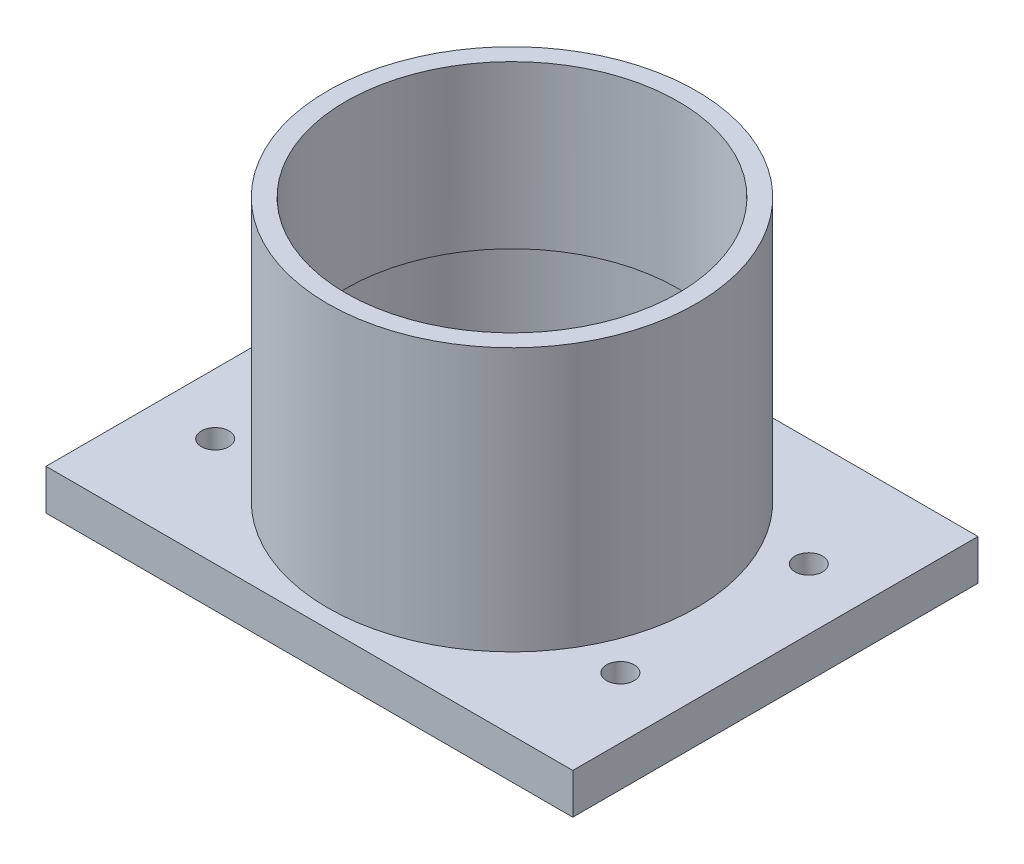
from build123d import *

# Parameters (mm, degrees)
SKETCH1_W             = 130
SKETCH1_H             = 100
BOSS_EXTRUDE1_DEPTH   = 10
SKETCH2_R             = 45.5
BOSS_EXTRUDE2_DEPTH   = 65
SKETCH3_R             = 41
CUT_EXTRUDE1_DEPTH    = 76
SKETCH4_R             = 42.5
CUT_EXTRUDE2_DEPTH    = 35
M8_TAPPED_HOLE1_D     = 6.8
M8_TAPPED_HOLE1_DEPTH = 17.707073895
M8_TAPPED_HOLE1_TIP   = 2.042926105


with BuildPart() as part:
    # Sketch1 → Boss-Extrude1 (new body)
    with BuildSketch(Plane(origin=(0, 0, 0), x_dir=(1, 0, 0), z_dir=(0, 1, 0))):
        Rectangle(SKETCH1_W, SKETCH1_H)
    extrude(amount=BOSS_EXTRUDE1_DEPTH)

    # Sketch2 → Boss-Extrude2 (add)
    with BuildSketch(Plane(origin=(0, 10, 0), x_dir=(1, 0, 0), z_dir=(0, 1, 0))):
        Circle(SKETCH2_R)
    extrude(amount=BOSS_EXTRUDE2_DEPTH)

    # Sketch3 → Cut-Extrude1 (cut, through all)
    with BuildSketch(Plane(origin=(0, 75, 0), x_dir=(1, 0, 0), z_dir=(0, 1, 0))):
        Circle(SKETCH3_R)
    extrude(amount=-CUT_EXTRUDE1_DEPTH, mode=Mode.SUBTRACT)

    # Sketch4 → Cut-Extrude2 (cut)
    with BuildSketch(Plane.XZ):
        Circle(SKETCH4_R)
    extrude(amount=-CUT_EXTRUDE2_DEPTH, mode=Mode.SUBTRACT)

    # M8 Tapped Hole1
    with Locations(Plane(origin=(0, 10, 0), x_dir=(1, 0, 0), z_dir=(0, 1, 0))):
        with Locations((-50, 23.25), (-50, -23.25), (50, -23.25), (50, 23.25)):
            Hole(M8_TAPPED_HOLE1_D / 2, depth=M8_TAPPED_HOLE1_DEPTH)
            with Locations((0, 0, -(M8_TAPPED_HOLE1_DEPTH + M8_TAPPED_HOLE1_TIP / 2))):  # 118° drill point
                Cone(0, M8_TAPPED_HOLE1_D / 2, M8_TAPPED_HOLE1_TIP, mode=Mode.SUBTRACT)


solid = part.part
